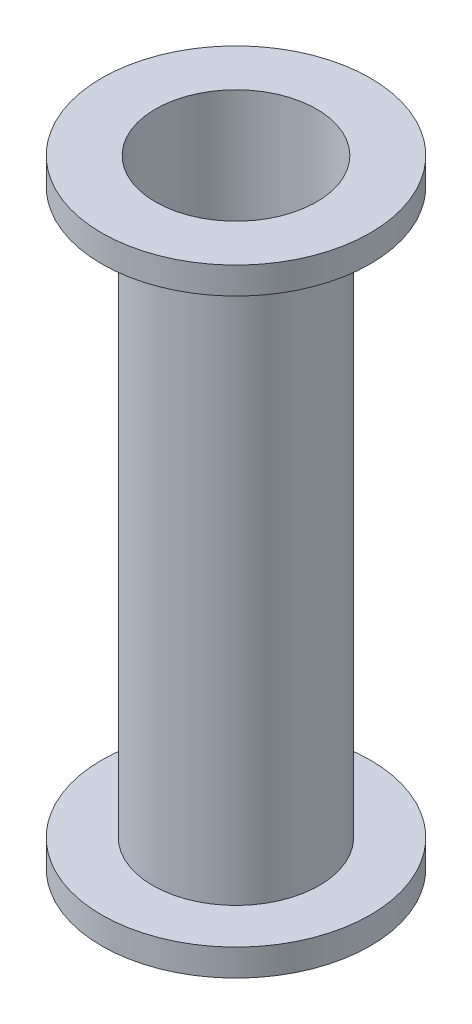
from build123d import *

# Parameters (mm, degrees)
SKETCH2_R            = 39.37
SKETCH2_R_2          = 38.1
BASE_CYLINDER_DEPTH  = 292.1
SKETCH3_R            = 63.5
SKETCH3_R_2          = 38.1
AFT_FLANGE_DEPTH     = 12.7
SKETCH4_R            = 63.5
SKETCH4_R_2          = 38.1
FORWARD_FLANGE_DEPTH = 12.7


with BuildPart() as part:
    # Sketch2 → Base Cylinder (new body)
    with BuildSketch(Plane(origin=(0, 0, 0), x_dir=(1, 0, 0), z_dir=(0, 1, 0))):
        Circle(SKETCH2_R)
        Circle(SKETCH2_R_2, mode=Mode.SUBTRACT)
    extrude(amount=BASE_CYLINDER_DEPTH)

    # Sketch3 → Aft Flange (add)
    with BuildSketch(Plane.XZ):
        Circle(SKETCH3_R)
        Circle(SKETCH3_R_2, mode=Mode.SUBTRACT)
    extrude(amount=-AFT_FLANGE_DEPTH)

    # Sketch4 → Forward Flange (add)
    with BuildSketch(Plane(origin=(0, 292.1, 0), x_dir=(1, 0, 0), z_dir=(0, 1, 0))):
        Circle(SKETCH4_R)
        Circle(SKETCH4_R_2, mode=Mode.SUBTRACT)
    extrude(amount=-FORWARD_FLANGE_DEPTH)


solid = part.part
